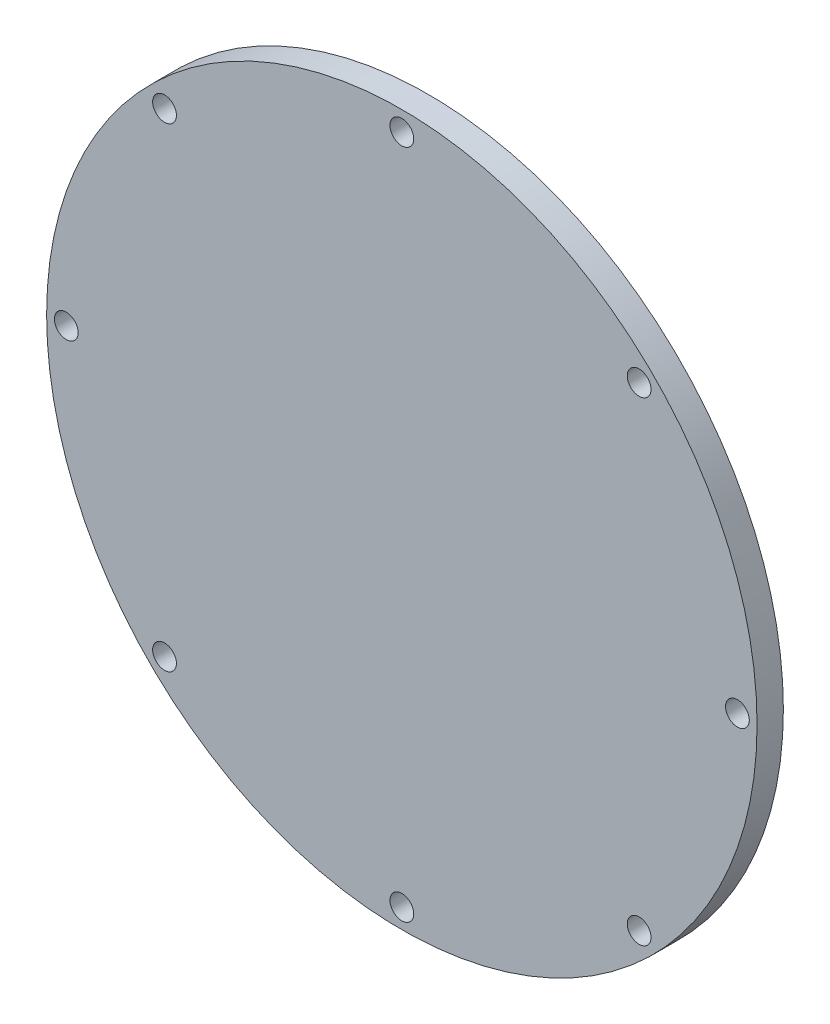
from build123d import *

# Parameters (mm, degrees)
SKETCH1_R                      = 75.565
BOSS_EXTRUDE1_DEPTH            = 5.6
F_8_0_199_DIAMETER_HOLE1_D     = 5.0546
F_8_0_199_DIAMETER_HOLE1_DEPTH = 8.481444958
F_8_0_199_DIAMETER_HOLE1_TIP   = 1.518555042


with BuildPart() as part:
    # Sketch1 → Boss-Extrude1 (new body)
    with BuildSketch(Plane.XY):
        Circle(SKETCH1_R)
    extrude(amount=BOSS_EXTRUDE1_DEPTH)

    # #8 (0.199) Diameter Hole1
    with Locations(Plane(origin=(0, 0, 0), x_dir=(-1, 0, 0), z_dir=(0, 0, -1))):
        with Locations((-50.478019657, 50.478019657), (0, 71.3867), (50.478019657, 50.478019657), (71.3867, 0), (50.478019657, -50.478019657), (0, -71.3867), (-50.478019657, -50.478019657), (-71.3867, 0)):
            Hole(F_8_0_199_DIAMETER_HOLE1_D / 2, depth=F_8_0_199_DIAMETER_HOLE1_DEPTH)
            with Locations((0, 0, -(F_8_0_199_DIAMETER_HOLE1_DEPTH + F_8_0_199_DIAMETER_HOLE1_TIP / 2))):  # 118° drill point
                Cone(0, F_8_0_199_DIAMETER_HOLE1_D / 2, F_8_0_199_DIAMETER_HOLE1_TIP, mode=Mode.SUBTRACT)


solid = part.part
